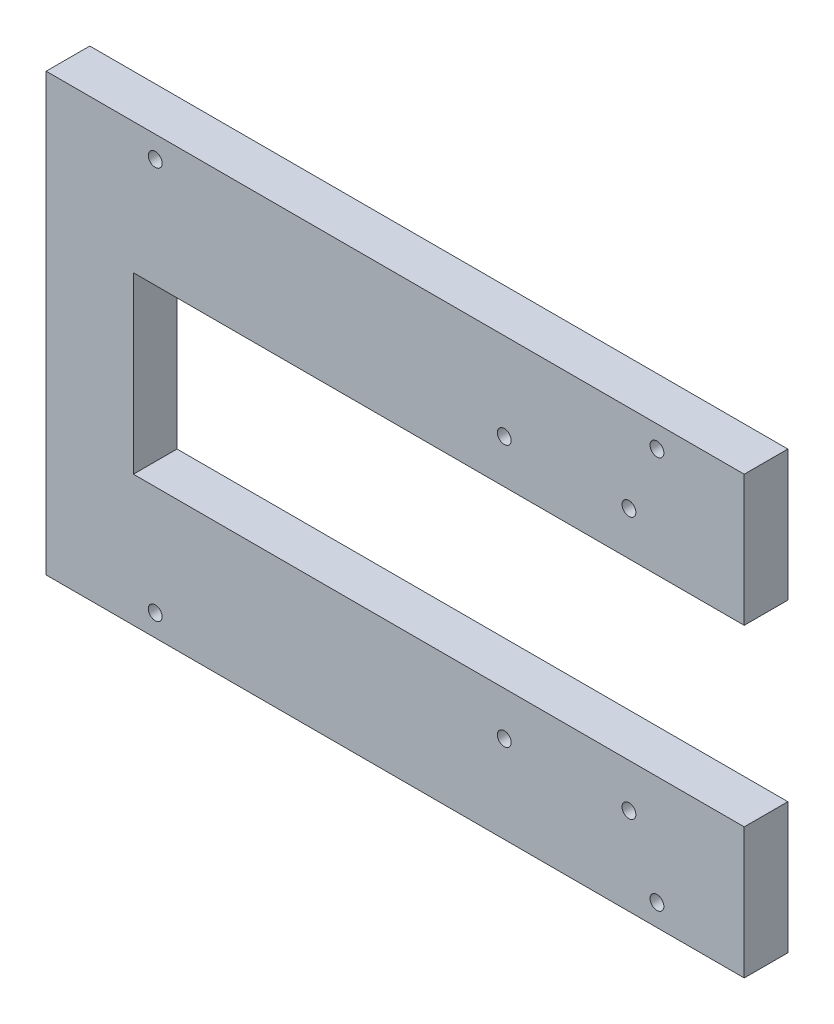
from build123d import *

# Parameters (mm, degrees)
SKETCH1_R           = 1.5875
BOSS_EXTRUDE1_DEPTH = 10


with BuildPart() as part:
    # Sketch1 → Boss-Extrude1 (new body)
    with BuildSketch(Plane.XY):
        Polygon((-53.537623716, 64.885018665), (106.462376284, 64.885018665), (106.462376284, 34.885018665), (-33.537623716, 34.885018665), (-33.537623716, -5.114981335), (106.462376284, -5.114981335), (106.462376284, -35.114981335), (-53.537623716, -35.114981335), align=None)
        with Locations((51.462376284, 44.885018665)):
            Circle(SKETCH1_R, mode=Mode.SUBTRACT)
        with Locations((80.037376284, 44.885018665)):
            Circle(SKETCH1_R, mode=Mode.SUBTRACT)
        with Locations((51.462376284, -15.114981335)):
            Circle(SKETCH1_R, mode=Mode.SUBTRACT)
        with Locations((80.037376284, -15.114981335)):
            Circle(SKETCH1_R, mode=Mode.SUBTRACT)
        with Locations((-28.537623716, 59.885018665)):
            Circle(SKETCH1_R, mode=Mode.SUBTRACT)
        with Locations((86.462376284, 59.885018665)):
            Circle(SKETCH1_R, mode=Mode.SUBTRACT)
        with Locations((-28.537623716, -30.114981335)):
            Circle(SKETCH1_R, mode=Mode.SUBTRACT)
        with Locations((86.462376284, -30.114981335)):
            Circle(SKETCH1_R, mode=Mode.SUBTRACT)
    extrude(amount=BOSS_EXTRUDE1_DEPTH)


solid = part.part
